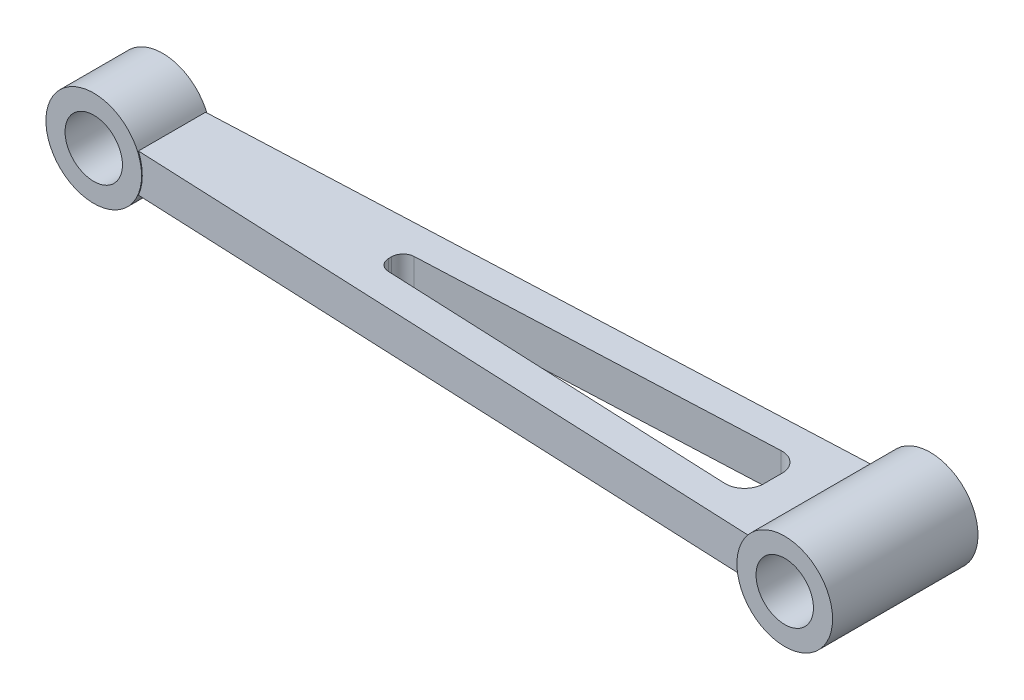
from build123d import *

# Parameters (mm, degrees)
BOSS_EXTRUDE1_DEPTH      = 10
BOSS_EXTRUDE2_DEPTH      = 9
BOSS_EXTRUDE2_DEPTH_BACK = 9
SKETCH2_R                = 12.5
SKETCH3_R                = 7.5
CUT_EXTRUDE1_DEPTH       = 113.046768917
BOSS_EXTRUDE3_DEPTH      = 19
BOSS_EXTRUDE3_DEPTH_BACK = 19
SKETCH4_R                = 12.5
SKETCH5_R                = 7.5
CUT_EXTRUDE2_DEPTH       = 116.614784522


with BuildPart() as part:
    # Sketch1 → Boss-Extrude1 (new body)
    with BuildSketch(Plane(origin=(0, 0, 0), x_dir=(1, 0, 0), z_dir=(0, 1, 0))):
        with BuildLine():
            Line((84.78, 16.133643284), (-84.78, 8.730493804))
            Line((-84.78, 8.730493804), (-84.78, 0))
            Line((-84.78, 0), (-26.81549416, 0))
            Line((-26.81549416, 0), (-26.81549416, 0.381782076))
            ThreePointArc((-26.81549416, 0.381782076), (-25.982586046, 2.456321244), (-23.946352322, 3.378926741))
            Line((-23.946352322, 3.378926741), (67.966408903, 7.391924561))
            ThreePointArc((67.966408903, 7.391924561), (71.642071119, 6.008503264), (73.18450584, 2.396683453))
            Line((73.18450584, 2.396683453), (73.18450584, 0))
            Line((73.18450584, 0), (84.78, 0))
            Line((84.78, 0), (84.78, 16.133643284))
        make_face()
    boss_extrude1 = extrude(amount=BOSS_EXTRUDE1_DEPTH)

    # Mirror1: Boss-Extrude1 across plane
    add(boss_extrude1.mirror(Plane.XY))

    # Sketch2 → Boss-Extrude2 (add, two sides: drawn at the far end of the back side and taken through both)
    with BuildSketch(Plane.XY.offset(-BOSS_EXTRUDE2_DEPTH_BACK)):
        with Locations((-95.28, 5)):
            Circle(SKETCH2_R)
    extrude(amount=BOSS_EXTRUDE2_DEPTH + BOSS_EXTRUDE2_DEPTH_BACK)

    # Sketch3 → Cut-Extrude1 (cut, through all)
    with BuildSketch(Plane.XY.offset(9)):
        with Locations((-95.28, 5)):
            Circle(SKETCH3_R)
    extrude(amount=-CUT_EXTRUDE1_DEPTH, mode=Mode.SUBTRACT)

    # Sketch4 → Boss-Extrude3 (add, two sides: drawn at the far end of the back side and taken through both)
    with BuildSketch(Plane.XY.offset(-BOSS_EXTRUDE3_DEPTH_BACK)):
        with Locations((95.28, 5)):
            Circle(SKETCH4_R)
    extrude(amount=BOSS_EXTRUDE3_DEPTH + BOSS_EXTRUDE3_DEPTH_BACK)

    # Sketch5 → Cut-Extrude2 (cut, through all)
    with BuildSketch(Plane.XY.offset(19)):
        with Locations((95.28, 5)):
            Circle(SKETCH5_R)
    extrude(amount=-CUT_EXTRUDE2_DEPTH, mode=Mode.SUBTRACT)


solid = part.part
